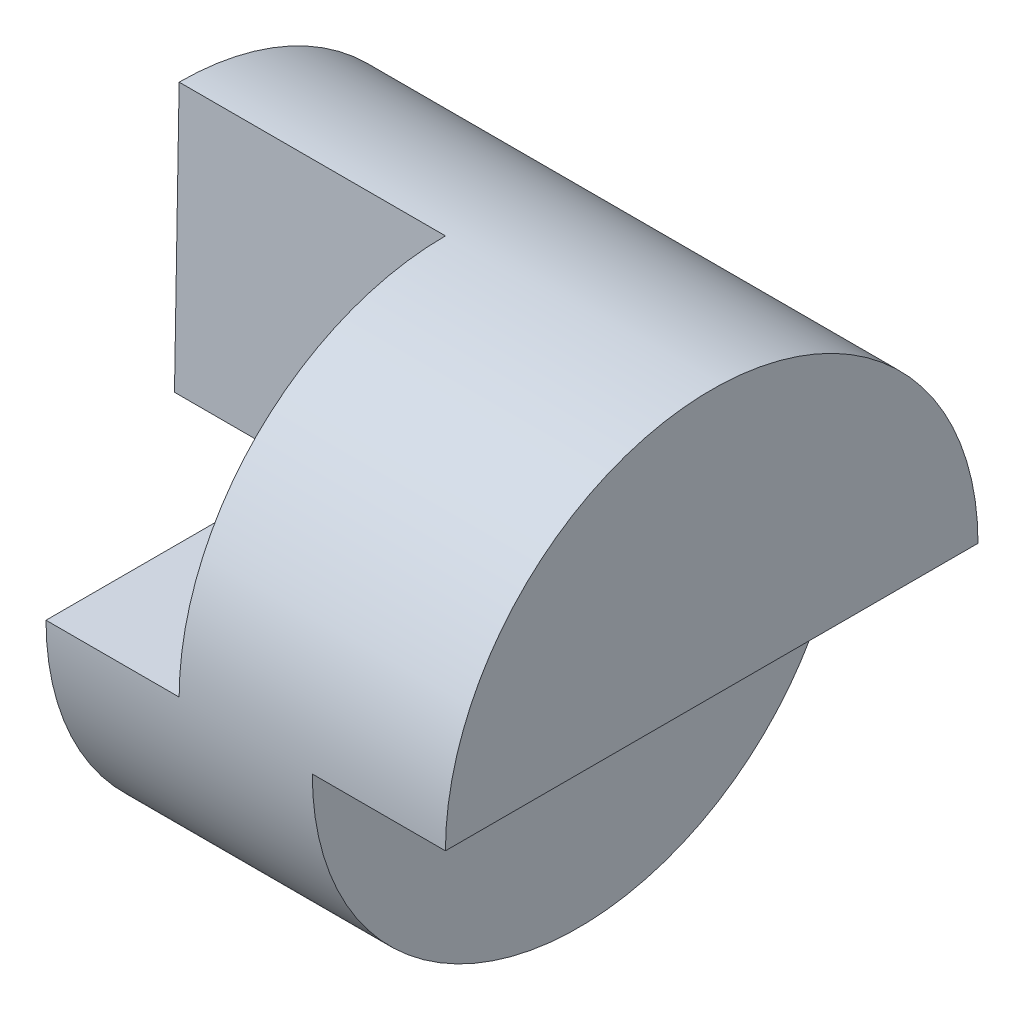
from build123d import *

# Parameters (mm, degrees)
SKETCH5_W           = 4
SKETCH5_H           = 2
SKETCH6_W           = 1
SKETCH6_H           = 2
CUT_EXTRUDE5_DEPTH  = 11
SKETCH8_W           = 0.5
SKETCH8_H           = 2
CUT_EXTRUDE7_DEPTH  = 10
SKETCH9_W           = 1.5
SKETCH9_H           = 2
CUT_EXTRUDE8_DEPTH  = 10
BOSS_EXTRUDE1_DEPTH = 4
SKETCH13_W          = 4.449870591
SKETCH13_H          = 3.198188742
CUT_EXTRUDE10_DEPTH = 1
SKETCH14_W          = 1
SKETCH14_H          = 2
CUT_EXTRUDE11_DEPTH = 5


with BuildPart() as part:
    # Sketch5 → Revolve-Thin2 (revolve)
    with BuildSketch(Plane.XY):
        with Locations((2, 1)):
            Rectangle(SKETCH5_W, SKETCH5_H)
    revolve(axis=Axis((0, 0, 0), (1, 0, 0)))

    # Sketch6 → Cut-Extrude5 (cut)
    with BuildSketch(Plane.XY):
        with Locations((3.5, 1)):
            Rectangle(SKETCH6_W, SKETCH6_H)
        with Locations((0.5, 1)):
            Rectangle(SKETCH6_W, SKETCH6_H)
    extrude(amount=-CUT_EXTRUDE5_DEPTH, mode=Mode.SUBTRACT)

    # Sketch8 → Cut-Extrude7 (cut)
    with BuildSketch(Plane(origin=(0, 0, 0), x_dir=(-1, 0, 0), z_dir=(0, 0, -1))):
        with Locations((-0.25, 1)):
            Rectangle(SKETCH8_W, SKETCH8_H)
    extrude(amount=-CUT_EXTRUDE7_DEPTH, mode=Mode.SUBTRACT)

    # Sketch9 → Cut-Extrude8 (cut)
    with BuildSketch(Plane(origin=(0, 0, 0), x_dir=(-1, 0, 0), z_dir=(0, 0, -1))):
        with Locations((-1.25, 1)):
            Rectangle(SKETCH9_W, SKETCH9_H)
    extrude(amount=-CUT_EXTRUDE8_DEPTH, mode=Mode.SUBTRACT)

    # Sketch10 → Boss-Extrude1 (add)
    with BuildSketch(Plane(origin=(4, 0, 0), x_dir=(0, 0, -1), z_dir=(1, 0, 0))):
        with BuildLine():
            Line((2, 0), (-0.034977088, 0))
            Line((-0.034977088, 0), (0, 2))
            ThreePointArc((0, 2), (1.414213562, 1.414213562), (2, 0))
        make_face()
    extrude(amount=-BOSS_EXTRUDE1_DEPTH)

    # Sketch13 → Cut-Extrude10 (cut)
    with BuildSketch(Plane.ZY):
        with Locations((-0.224935296, -1.599094371)):
            Rectangle(SKETCH13_W, SKETCH13_H)
    extrude(amount=-CUT_EXTRUDE10_DEPTH, mode=Mode.SUBTRACT)

    # Sketch14 → Cut-Extrude11 (cut, symmetric)
    with BuildSketch(Plane.XY):
        with Locations((3.5, -1)):
            Rectangle(SKETCH14_W, SKETCH14_H)
    extrude(amount=CUT_EXTRUDE11_DEPTH, both=True, mode=Mode.SUBTRACT)


solid = part.part
